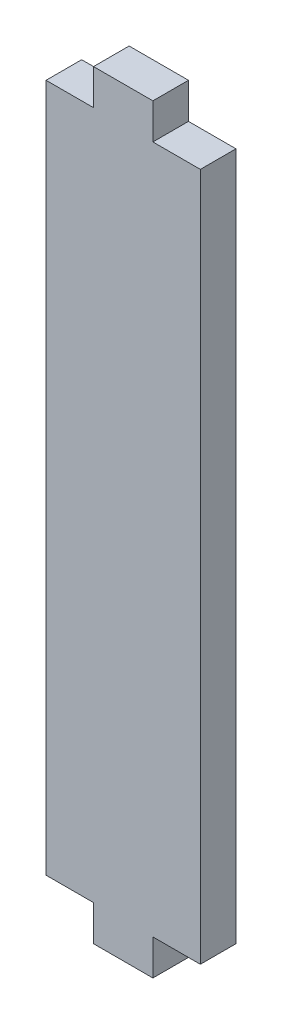
from build123d import *

# Parameters (mm, degrees)
SALIENTE_EXTRUIR1_DEPTH = 3


with BuildPart() as part:
    # Croquis1 → Saliente-Extruir1 (new body)
    with BuildSketch(Plane.XY):
        Polygon((-6.5, 29), (-2.5, 29), (-2.5, 32), (2.5, 32), (2.5, 29), (6.5, 29), (6.5, -29), (2.5, -29), (2.5, -32), (-2.5, -32), (-2.5, -29), (-6.5, -29), align=None)
    extrude(amount=SALIENTE_EXTRUIR1_DEPTH)


solid = part.part
